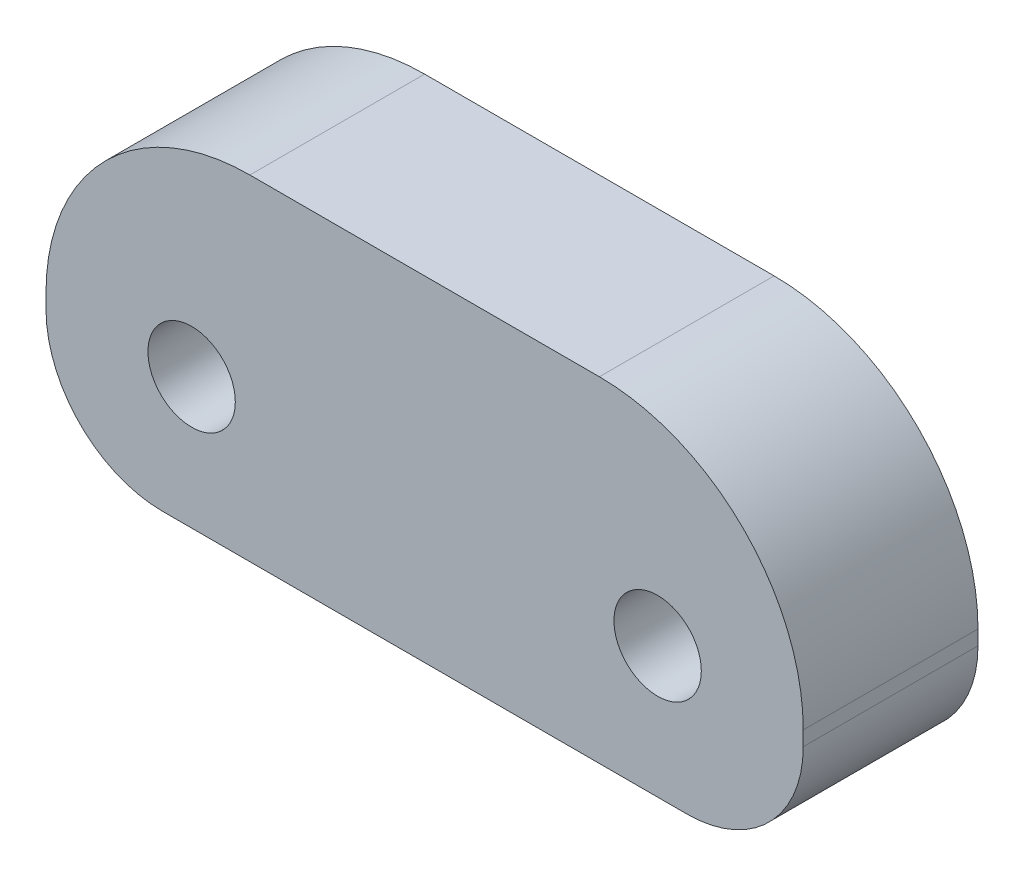
from build123d import *

# Parameters (mm, degrees)
ESBO_O1_W                = 26
ESBO_O1_H                = 11.5
ESBO_O1_R                = 1.5
RESSALTO_EXTRUS_O1_DEPTH = 6
FILETE1_R                = 7
FILETE2_R                = 4


with BuildPart() as part:
    # Esboço1 → Ressalto-extrusão1 (new body)
    with BuildSketch(Plane.XY):
        Rectangle(ESBO_O1_W, ESBO_O1_H)
        with Locations((-8, -1.25)):
            Circle(ESBO_O1_R, mode=Mode.SUBTRACT)
        with Locations((8, -1.25)):
            Circle(ESBO_O1_R, mode=Mode.SUBTRACT)
    extrude(amount=RESSALTO_EXTRUS_O1_DEPTH)

    # Filete1
    filete1_edges = [part.edges().sort_by_distance(p)[0] for p in [
        (-13, 5.75, 3),
        (13, 5.75, 3),
    ]]
    fillet(filete1_edges, radius=FILETE1_R)

    # Filete2
    filete2_edges = [part.edges().sort_by_distance(p)[0] for p in [
        (-13, -5.75, 3),
        (13, -5.75, 3),
    ]]
    fillet(filete2_edges, radius=FILETE2_R)


solid = part.part
